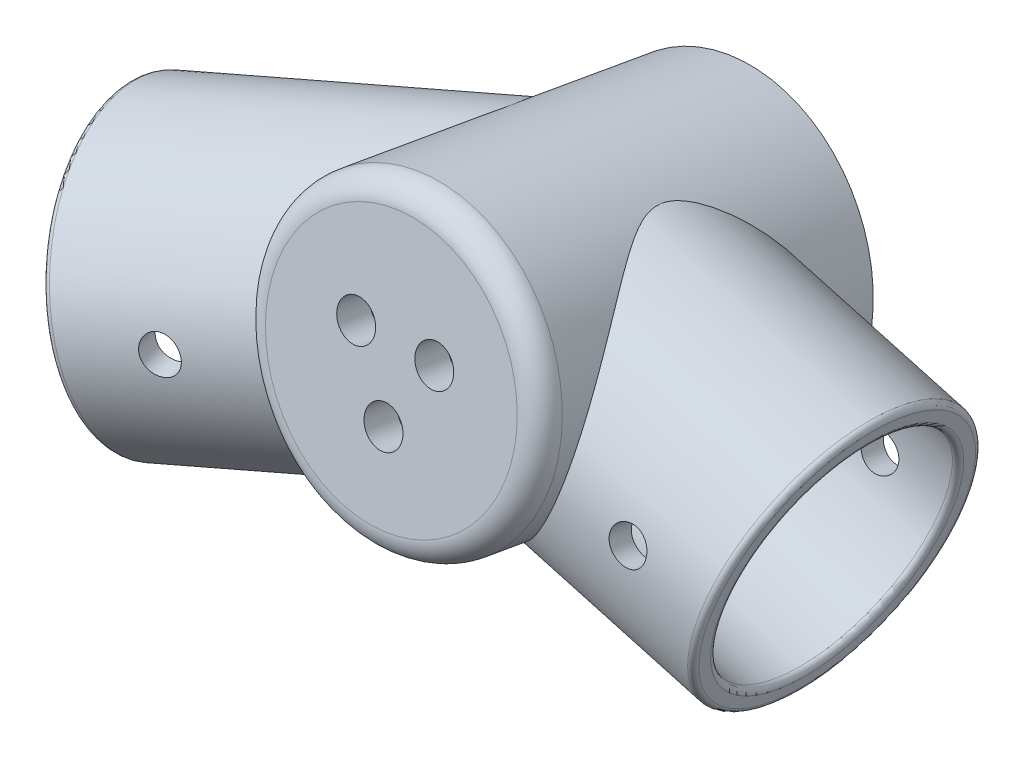
from build123d import *

# Parameters (mm, degrees)
SKETCH1_R               = 13
BOSS_EXTRUDE1_DEPTH     = 30
SKETCH2_R               = 8.5
CUT_EXTRUDE1_DEPTH      = 27
SKETCH3_R               = 1.7
CUT_EXTRUDE3_DEPTH      = 35.446261863
BOSS_EXTRUDE3_REACH     = 44.343
SKETCH9_R               = 12.35
SKETCH9_R_2             = 10.35
SKETCH17_R              = 1.5875
CUT_EXTRUDE4_DEPTH      = 35.446261979
CUT_EXTRUDE4_DEPTH_BACK = 6.030493347
BOSS_EXTRUDE4_REACH     = 68.67
SKETCH14_R              = 12.35
SKETCH14_R_2            = 10.35
SKETCH18_R              = 1.5875
CUT_EXTRUDE5_DEPTH      = 38.801193315
CUT_EXTRUDE5_DEPTH_BACK = 11.6122478
FILLET2_R               = 0.5
FILLET3_R               = 2


with BuildPart() as part:
    # Sketch1 → Boss-Extrude1 (new body)
    with BuildSketch(Plane(origin=(0, 0, 0), x_dir=(1, 0, 0), z_dir=(0, 0.173648178, 0.984807753))):
        Circle(SKETCH1_R)
    extrude(amount=BOSS_EXTRUDE1_DEPTH)

    # Sketch2 → Cut-Extrude1 (cut)
    with BuildSketch(Plane(origin=(0, 0, 0), x_dir=(1, 0, 0), z_dir=(0, 0.173648178, 0.984807753))):
        Circle(SKETCH2_R)
    extrude(amount=CUT_EXTRUDE1_DEPTH, mode=Mode.SUBTRACT)

    # Sketch3 → Cut-Extrude3 (cut, through all)
    with BuildSketch(Plane(origin=(0, 5.20944533, 29.54423259), x_dir=(1, 0, 0), z_dir=(0, 0.173648178, 0.984807753))):
        with Locations((0, -4)):
            Circle(SKETCH3_R)
        with Locations((-3.464101615, 2)):
            Circle(SKETCH3_R)
        with Locations((3.464101615, 2)):
            Circle(SKETCH3_R)
    extrude(amount=-CUT_EXTRUDE3_DEPTH, mode=Mode.SUBTRACT)

    # Sketch9 → Boss-Extrude3 (add, up to next)
    with BuildSketch(Plane(origin=(24.089594916, -6.685163931, 0), x_dir=(0, 0, -1), z_dir=(0.963583797, -0.267406557, 0)), mode=Mode.PRIVATE) as boss_extrude3_sk1:
        with Locations((-14.772116295, 2.509868555)):
            Circle(SKETCH9_R)
        with Locations((-14.772116295, 2.509868555)):
            Circle(SKETCH9_R_2, mode=Mode.SUBTRACT)
    boss_extrude3_tool1 = extrude(boss_extrude3_sk1.sketch, amount=-BOSS_EXTRUDE3_REACH, mode=Mode.PRIVATE) - part.part
    add(boss_extrude3_tool1.solids().sort_by_distance((24.76075, -4.266695, 26.772806))[0])

    # Sketch17 → Cut-Extrude4 (cut, two sides)
    with BuildSketch(Plane(origin=(0, 0, 0), x_dir=(1, 0, 0), z_dir=(0, 0.173648178, 0.984807753))) as cut_extrude4_sk:
        with Locations((18.373842499, -5.021506307)):
            Circle(SKETCH17_R)
    extrude(amount=CUT_EXTRUDE4_DEPTH, mode=Mode.SUBTRACT)
    extrude(cut_extrude4_sk.sketch, amount=-CUT_EXTRUDE4_DEPTH_BACK, mode=Mode.SUBTRACT)

    # Sketch14 → Boss-Extrude4 (add, up to next)
    with BuildSketch(Plane(origin=(-32.655763579, -9.647307454, 8.095095056), x_dir=(0.224638917, 0.055916921, 0.972836397), z_dir=(-0.933021817, -0.275637356, 0.23128843)), mode=Mode.PRIVATE) as boss_extrude4_sk1:
        with Locations((12.187405373, 2.267896436)):
            Circle(SKETCH14_R)
        with Locations((12.187405373, 2.267896436)):
            Circle(SKETCH14_R_2, mode=Mode.SUBTRACT)
    boss_extrude4_tool1 = extrude(boss_extrude4_sk1.sketch, amount=-BOSS_EXTRUDE4_REACH, mode=Mode.PRIVATE) - part.part
    add(boss_extrude4_tool1.solids().sort_by_distance((-33.251287, -7.460516, 8.298845))[0])

    # Sketch18 → Cut-Extrude5 (cut, two sides)
    with BuildSketch(Plane(origin=(0, 0, 0), x_dir=(0, 1, 0), z_dir=(0.240609223, 0, 0.970622069))) as cut_extrude5_sk:
        with Locations((-3.370579699, 26.669267717)):
            Circle(SKETCH18_R)
    extrude(amount=CUT_EXTRUDE5_DEPTH, mode=Mode.SUBTRACT)
    extrude(cut_extrude5_sk.sketch, amount=-CUT_EXTRUDE5_DEPTH_BACK, mode=Mode.SUBTRACT)

    # Fillet2
    fillet2_edges = [part.edges().sort_by_distance(p)[0] for p in [
        (24.760750225, -4.26669526, 27.122116295),
        (24.760750225, -4.26669526, 25.122116295),
        (-33.329755769, -7.480048797, 7.959022656),
        (-32.880477934, -7.368214955, 9.90469545),
    ]]
    fillet(fillet2_edges, radius=FILLET2_R)

    # Fillet3
    fillet3_edges = [part.edges().sort_by_distance(p)[0] for p in [
        (-13, 5.20944533, 29.54423259),
    ]]
    fillet(fillet3_edges, radius=FILLET3_R)


solid = part.part
